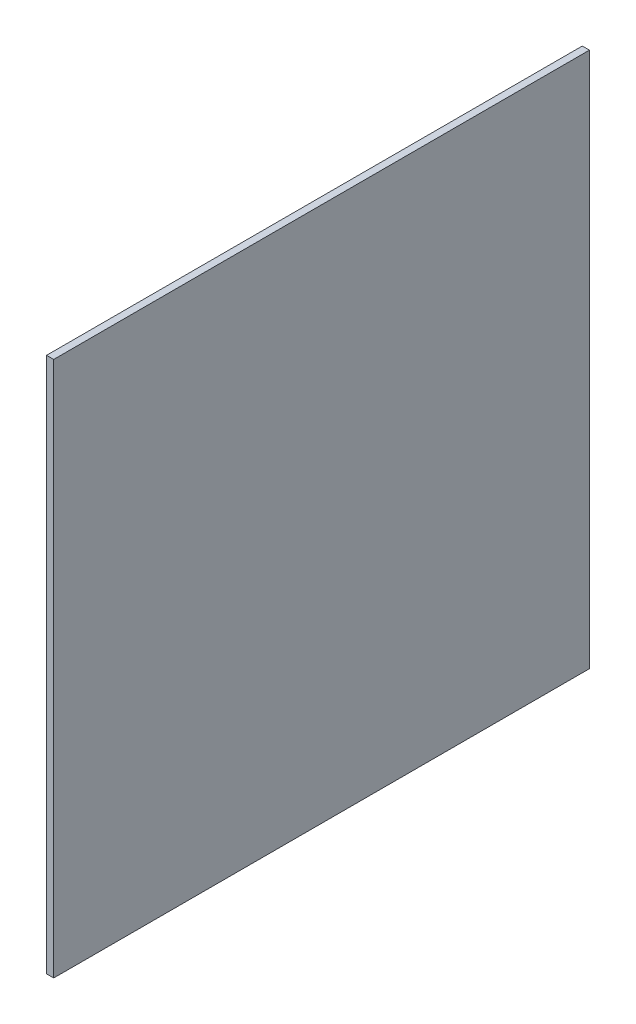
from build123d import *

# Parameters (mm, degrees)
SKETCH1_W           = 2
SKETCH1_H           = 150
BOSS_EXTRUDE1_DEPTH = 150


with BuildPart() as part:
    # Sketch1 → Boss-Extrude1 (new body)
    with BuildSketch(Plane.XY):
        with Locations((-74, 0)):
            Rectangle(SKETCH1_W, SKETCH1_H)
    extrude(amount=BOSS_EXTRUDE1_DEPTH)


solid = part.part
